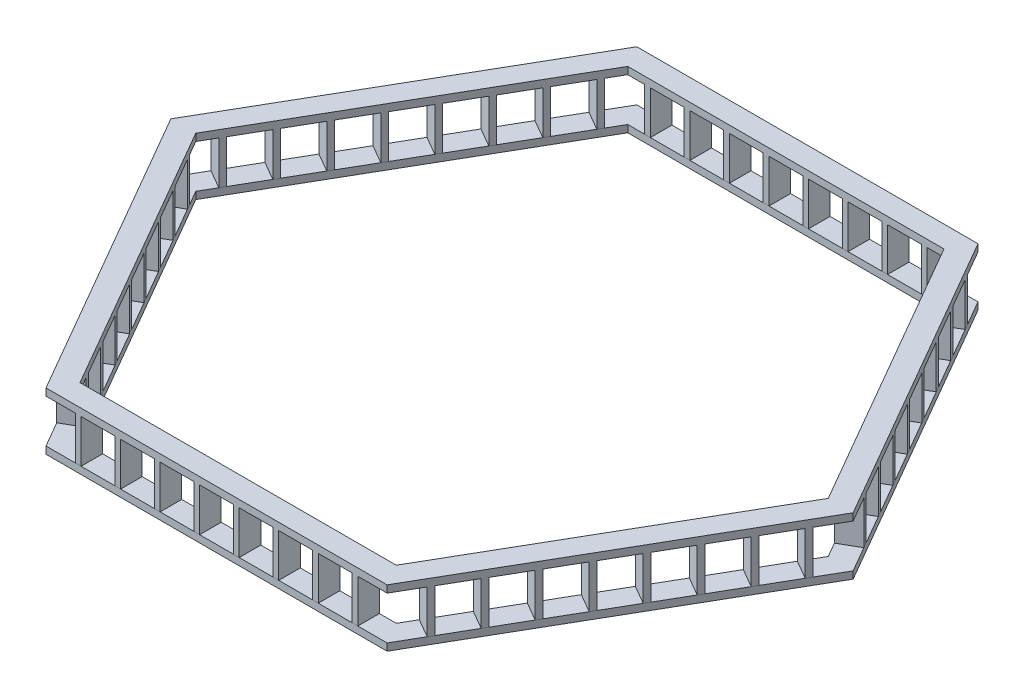
from build123d import *

# Parameters (mm, degrees)
EXTRUDE_2_DEPTH          = 50
SKETCH_2_W               = 40
SKETCH_2_H               = 150
EXTRUDE_3_DEPTH          = 300
EXTRUDE_3_2_DEPTH        = 300
EXTRUDE_3_3_DEPTH        = 300
EXTRUDE_3_4_DEPTH        = 300
EXTRUDE_3_5_DEPTH        = 300
EXTRUDE_3_6_DEPTH        = 300
EXTRUDE_3_7_DEPTH        = 300
EXTRUDE_3_8_DEPTH        = 300
PATTERN_CIRCULAR_2_COUNT = 6
EXTRUDE_5_DEPTH          = 50


with BuildPart() as part:
    # 草图1 → 凸台-拉伸2 (new body)
    with BuildSketch(Plane(origin=(0, 0, 0), x_dir=(1, 0, 0), z_dir=(0, 1, 0))):
        Polygon((-1186.602540378, -2055.255888326), (1186.602540378, -2055.255888326), (2373.205080757, 0), (1186.602540378, 2055.255888326), (-1186.602540378, 2055.255888326), (-2373.205080757, 0), align=None)
        Polygon((-1100, -1905.255888326), (1100, -1905.255888326), (2200, 0), (1100, 1905.255888326), (-1100, 1905.255888326), (-2200, 0), align=None, mode=Mode.SUBTRACT)
    extrude(amount=EXTRUDE_2_DEPTH)


with BuildPart() as body_2:
    # 草图2 → 凸台-拉伸3 (new body)
    with BuildSketch(Plane(origin=(0, 50, 0), x_dir=(1, 0, 0), z_dir=(0, 1, 0))):
        with Locations((137.5, 1980.255888326)):
            Rectangle(SKETCH_2_W, SKETCH_2_H)
    extrude(amount=EXTRUDE_3_DEPTH)


with BuildPart() as body_3:
    # 草图2 → Extrude 3 2 (new body)
    with BuildSketch(Plane(origin=(0, 50, 0), x_dir=(1, 0, 0), z_dir=(0, 1, 0))):
        with Locations((412.5, 1980.255888326)):
            Rectangle(SKETCH_2_W, SKETCH_2_H)
    extrude(amount=EXTRUDE_3_2_DEPTH)


with BuildPart() as body_4:
    # 草图2 → Extrude 3 3 (new body)
    with BuildSketch(Plane(origin=(0, 50, 0), x_dir=(1, 0, 0), z_dir=(0, 1, 0))):
        with Locations((687.5, 1980.255888326)):
            Rectangle(SKETCH_2_W, SKETCH_2_H)
    extrude(amount=EXTRUDE_3_3_DEPTH)


with BuildPart() as body_5:
    # 草图2 → Extrude 3 4 (new body)
    with BuildSketch(Plane(origin=(0, 50, 0), x_dir=(1, 0, 0), z_dir=(0, 1, 0))):
        with Locations((962.5, 1980.255888326)):
            Rectangle(SKETCH_2_W, SKETCH_2_H)
    extrude(amount=EXTRUDE_3_4_DEPTH)


with BuildPart() as body_6:
    # 草图2 → Extrude 3 5 (new body)
    with BuildSketch(Plane(origin=(0, 50, 0), x_dir=(1, 0, 0), z_dir=(0, 1, 0))):
        with Locations((-412.5, 1980.255888326)):
            Rectangle(SKETCH_2_W, SKETCH_2_H)
    extrude(amount=EXTRUDE_3_5_DEPTH)


with BuildPart() as body_7:
    # 草图2 → Extrude 3 6 (new body)
    with BuildSketch(Plane(origin=(0, 50, 0), x_dir=(1, 0, 0), z_dir=(0, 1, 0))):
        with Locations((-962.5, 1980.255888326)):
            Rectangle(SKETCH_2_W, SKETCH_2_H)
    extrude(amount=EXTRUDE_3_6_DEPTH)


with BuildPart() as body_8:
    # 草图2 → Extrude 3 7 (new body)
    with BuildSketch(Plane(origin=(0, 50, 0), x_dir=(1, 0, 0), z_dir=(0, 1, 0))):
        with Locations((-687.5, 1980.255888326)):
            Rectangle(SKETCH_2_W, SKETCH_2_H)
    extrude(amount=EXTRUDE_3_7_DEPTH)


with BuildPart() as body_9:
    # 草图2 → Extrude 3 8 (new body)
    with BuildSketch(Plane(origin=(0, 50, 0), x_dir=(1, 0, 0), z_dir=(0, 1, 0))):
        with Locations((-137.5, 1980.255888326)):
            Rectangle(SKETCH_2_W, SKETCH_2_H)
    extrude(amount=EXTRUDE_3_8_DEPTH)


with BuildPart() as pattern_circular_2_1:
    # 阵列(圆周)2: pattern copy
    add(body_5.part.rotate(Axis((0, 0, 0), (0, 1, 0)), 1 * 360 / PATTERN_CIRCULAR_2_COUNT))


with BuildPart() as pattern_circular_2_2:
    # 阵列(圆周)2: pattern copy
    add(body_5.part.rotate(Axis((0, 0, 0), (0, 1, 0)), 2 * 360 / PATTERN_CIRCULAR_2_COUNT))


with BuildPart() as pattern_circular_2_3:
    # 阵列(圆周)2: pattern copy
    add(body_5.part.rotate(Axis((0, 0, 0), (0, 1, 0)), 3 * 360 / PATTERN_CIRCULAR_2_COUNT))


with BuildPart() as pattern_circular_2_4:
    # 阵列(圆周)2: pattern copy
    add(body_5.part.rotate(Axis((0, 0, 0), (0, 1, 0)), 4 * 360 / PATTERN_CIRCULAR_2_COUNT))


with BuildPart() as pattern_circular_2_5:
    # 阵列(圆周)2: pattern copy
    add(body_5.part.rotate(Axis((0, 0, 0), (0, 1, 0)), 5 * 360 / PATTERN_CIRCULAR_2_COUNT))


with BuildPart() as pattern_circular_2_6:
    # 阵列(圆周)2: pattern copy
    add(body_3.part.rotate(Axis((0, 0, 0), (0, 1, 0)), 1 * 360 / PATTERN_CIRCULAR_2_COUNT))


with BuildPart() as pattern_circular_2_7:
    # 阵列(圆周)2: pattern copy
    add(body_3.part.rotate(Axis((0, 0, 0), (0, 1, 0)), 2 * 360 / PATTERN_CIRCULAR_2_COUNT))


with BuildPart() as pattern_circular_2_8:
    # 阵列(圆周)2: pattern copy
    add(body_3.part.rotate(Axis((0, 0, 0), (0, 1, 0)), 3 * 360 / PATTERN_CIRCULAR_2_COUNT))


with BuildPart() as pattern_circular_2_9:
    # 阵列(圆周)2: pattern copy
    add(body_3.part.rotate(Axis((0, 0, 0), (0, 1, 0)), 4 * 360 / PATTERN_CIRCULAR_2_COUNT))


with BuildPart() as pattern_circular_2_10:
    # 阵列(圆周)2: pattern copy
    add(body_3.part.rotate(Axis((0, 0, 0), (0, 1, 0)), 5 * 360 / PATTERN_CIRCULAR_2_COUNT))


with BuildPart() as pattern_circular_2_11:
    # 阵列(圆周)2: pattern copy
    add(body_7.part.rotate(Axis((0, 0, 0), (0, 1, 0)), 1 * 360 / PATTERN_CIRCULAR_2_COUNT))


with BuildPart() as pattern_circular_2_12:
    # 阵列(圆周)2: pattern copy
    add(body_7.part.rotate(Axis((0, 0, 0), (0, 1, 0)), 2 * 360 / PATTERN_CIRCULAR_2_COUNT))


with BuildPart() as pattern_circular_2_13:
    # 阵列(圆周)2: pattern copy
    add(body_7.part.rotate(Axis((0, 0, 0), (0, 1, 0)), 3 * 360 / PATTERN_CIRCULAR_2_COUNT))


with BuildPart() as pattern_circular_2_14:
    # 阵列(圆周)2: pattern copy
    add(body_7.part.rotate(Axis((0, 0, 0), (0, 1, 0)), 4 * 360 / PATTERN_CIRCULAR_2_COUNT))


with BuildPart() as pattern_circular_2_15:
    # 阵列(圆周)2: pattern copy
    add(body_7.part.rotate(Axis((0, 0, 0), (0, 1, 0)), 5 * 360 / PATTERN_CIRCULAR_2_COUNT))


with BuildPart() as pattern_circular_2_16:
    # 阵列(圆周)2: pattern copy
    add(body_8.part.rotate(Axis((0, 0, 0), (0, 1, 0)), 1 * 360 / PATTERN_CIRCULAR_2_COUNT))


with BuildPart() as pattern_circular_2_17:
    # 阵列(圆周)2: pattern copy
    add(body_8.part.rotate(Axis((0, 0, 0), (0, 1, 0)), 2 * 360 / PATTERN_CIRCULAR_2_COUNT))


with BuildPart() as pattern_circular_2_18:
    # 阵列(圆周)2: pattern copy
    add(body_8.part.rotate(Axis((0, 0, 0), (0, 1, 0)), 3 * 360 / PATTERN_CIRCULAR_2_COUNT))


with BuildPart() as pattern_circular_2_19:
    # 阵列(圆周)2: pattern copy
    add(body_8.part.rotate(Axis((0, 0, 0), (0, 1, 0)), 4 * 360 / PATTERN_CIRCULAR_2_COUNT))


with BuildPart() as pattern_circular_2_20:
    # 阵列(圆周)2: pattern copy
    add(body_8.part.rotate(Axis((0, 0, 0), (0, 1, 0)), 5 * 360 / PATTERN_CIRCULAR_2_COUNT))


with BuildPart() as pattern_circular_2_21:
    # 阵列(圆周)2: pattern copy
    add(body_6.part.rotate(Axis((0, 0, 0), (0, 1, 0)), 1 * 360 / PATTERN_CIRCULAR_2_COUNT))


with BuildPart() as pattern_circular_2_22:
    # 阵列(圆周)2: pattern copy
    add(body_6.part.rotate(Axis((0, 0, 0), (0, 1, 0)), 2 * 360 / PATTERN_CIRCULAR_2_COUNT))


with BuildPart() as pattern_circular_2_23:
    # 阵列(圆周)2: pattern copy
    add(body_6.part.rotate(Axis((0, 0, 0), (0, 1, 0)), 3 * 360 / PATTERN_CIRCULAR_2_COUNT))


with BuildPart() as pattern_circular_2_24:
    # 阵列(圆周)2: pattern copy
    add(body_6.part.rotate(Axis((0, 0, 0), (0, 1, 0)), 4 * 360 / PATTERN_CIRCULAR_2_COUNT))


with BuildPart() as pattern_circular_2_25:
    # 阵列(圆周)2: pattern copy
    add(body_6.part.rotate(Axis((0, 0, 0), (0, 1, 0)), 5 * 360 / PATTERN_CIRCULAR_2_COUNT))


with BuildPart() as pattern_circular_2_26:
    # 阵列(圆周)2: pattern copy
    add(body_9.part.rotate(Axis((0, 0, 0), (0, 1, 0)), 1 * 360 / PATTERN_CIRCULAR_2_COUNT))


with BuildPart() as pattern_circular_2_27:
    # 阵列(圆周)2: pattern copy
    add(body_9.part.rotate(Axis((0, 0, 0), (0, 1, 0)), 2 * 360 / PATTERN_CIRCULAR_2_COUNT))


with BuildPart() as pattern_circular_2_28:
    # 阵列(圆周)2: pattern copy
    add(body_9.part.rotate(Axis((0, 0, 0), (0, 1, 0)), 3 * 360 / PATTERN_CIRCULAR_2_COUNT))


with BuildPart() as pattern_circular_2_29:
    # 阵列(圆周)2: pattern copy
    add(body_9.part.rotate(Axis((0, 0, 0), (0, 1, 0)), 4 * 360 / PATTERN_CIRCULAR_2_COUNT))


with BuildPart() as pattern_circular_2_30:
    # 阵列(圆周)2: pattern copy
    add(body_9.part.rotate(Axis((0, 0, 0), (0, 1, 0)), 5 * 360 / PATTERN_CIRCULAR_2_COUNT))


with BuildPart() as pattern_circular_2_31:
    # 阵列(圆周)2: pattern copy
    add(body_2.part.rotate(Axis((0, 0, 0), (0, 1, 0)), 1 * 360 / PATTERN_CIRCULAR_2_COUNT))


with BuildPart() as pattern_circular_2_32:
    # 阵列(圆周)2: pattern copy
    add(body_2.part.rotate(Axis((0, 0, 0), (0, 1, 0)), 2 * 360 / PATTERN_CIRCULAR_2_COUNT))


with BuildPart() as pattern_circular_2_33:
    # 阵列(圆周)2: pattern copy
    add(body_2.part.rotate(Axis((0, 0, 0), (0, 1, 0)), 3 * 360 / PATTERN_CIRCULAR_2_COUNT))


with BuildPart() as pattern_circular_2_34:
    # 阵列(圆周)2: pattern copy
    add(body_2.part.rotate(Axis((0, 0, 0), (0, 1, 0)), 4 * 360 / PATTERN_CIRCULAR_2_COUNT))


with BuildPart() as pattern_circular_2_35:
    # 阵列(圆周)2: pattern copy
    add(body_2.part.rotate(Axis((0, 0, 0), (0, 1, 0)), 5 * 360 / PATTERN_CIRCULAR_2_COUNT))


with BuildPart() as pattern_circular_2_36:
    # 阵列(圆周)2: pattern copy
    add(body_4.part.rotate(Axis((0, 0, 0), (0, 1, 0)), 1 * 360 / PATTERN_CIRCULAR_2_COUNT))


with BuildPart() as pattern_circular_2_37:
    # 阵列(圆周)2: pattern copy
    add(body_4.part.rotate(Axis((0, 0, 0), (0, 1, 0)), 2 * 360 / PATTERN_CIRCULAR_2_COUNT))


with BuildPart() as pattern_circular_2_38:
    # 阵列(圆周)2: pattern copy
    add(body_4.part.rotate(Axis((0, 0, 0), (0, 1, 0)), 3 * 360 / PATTERN_CIRCULAR_2_COUNT))


with BuildPart() as pattern_circular_2_39:
    # 阵列(圆周)2: pattern copy
    add(body_4.part.rotate(Axis((0, 0, 0), (0, 1, 0)), 4 * 360 / PATTERN_CIRCULAR_2_COUNT))


with BuildPart() as pattern_circular_2_40:
    # 阵列(圆周)2: pattern copy
    add(body_4.part.rotate(Axis((0, 0, 0), (0, 1, 0)), 5 * 360 / PATTERN_CIRCULAR_2_COUNT))


with BuildPart() as body_2_1:
    add(body_2.part)

    add(body_3.part)  # 凸台-拉伸5 merges body 3

    add(body_4.part)  # 凸台-拉伸5 merges body 4

    add(body_5.part)  # 凸台-拉伸5 merges body 5

    add(body_6.part)  # 凸台-拉伸5 merges body 6

    add(body_7.part)  # 凸台-拉伸5 merges body 7

    add(body_8.part)  # 凸台-拉伸5 merges body 8

    add(body_9.part)  # 凸台-拉伸5 merges body 9

    add(pattern_circular_2_1.part)  # 凸台-拉伸5 merges 阵列(圆周)2_1

    add(pattern_circular_2_2.part)  # 凸台-拉伸5 merges 阵列(圆周)2_2

    add(pattern_circular_2_3.part)  # 凸台-拉伸5 merges 阵列(圆周)2_3

    add(pattern_circular_2_4.part)  # 凸台-拉伸5 merges 阵列(圆周)2_4

    add(pattern_circular_2_5.part)  # 凸台-拉伸5 merges 阵列(圆周)2_5

    add(pattern_circular_2_6.part)  # 凸台-拉伸5 merges 阵列(圆周)2_6

    add(pattern_circular_2_7.part)  # 凸台-拉伸5 merges 阵列(圆周)2_7

    add(pattern_circular_2_8.part)  # 凸台-拉伸5 merges 阵列(圆周)2_8

    add(pattern_circular_2_9.part)  # 凸台-拉伸5 merges 阵列(圆周)2_9

    add(pattern_circular_2_10.part)  # 凸台-拉伸5 merges 阵列(圆周)2_10

    add(pattern_circular_2_11.part)  # 凸台-拉伸5 merges 阵列(圆周)2_11

    add(pattern_circular_2_12.part)  # 凸台-拉伸5 merges 阵列(圆周)2_12

    add(pattern_circular_2_13.part)  # 凸台-拉伸5 merges 阵列(圆周)2_13

    add(pattern_circular_2_14.part)  # 凸台-拉伸5 merges 阵列(圆周)2_14

    add(pattern_circular_2_15.part)  # 凸台-拉伸5 merges 阵列(圆周)2_15

    add(pattern_circular_2_16.part)  # 凸台-拉伸5 merges 阵列(圆周)2_16

    add(pattern_circular_2_17.part)  # 凸台-拉伸5 merges 阵列(圆周)2_17

    add(pattern_circular_2_18.part)  # 凸台-拉伸5 merges 阵列(圆周)2_18

    add(pattern_circular_2_19.part)  # 凸台-拉伸5 merges 阵列(圆周)2_19

    add(pattern_circular_2_20.part)  # 凸台-拉伸5 merges 阵列(圆周)2_20

    add(pattern_circular_2_21.part)  # 凸台-拉伸5 merges 阵列(圆周)2_21

    add(pattern_circular_2_22.part)  # 凸台-拉伸5 merges 阵列(圆周)2_22

    add(pattern_circular_2_23.part)  # 凸台-拉伸5 merges 阵列(圆周)2_23

    add(pattern_circular_2_24.part)  # 凸台-拉伸5 merges 阵列(圆周)2_24

    add(pattern_circular_2_25.part)  # 凸台-拉伸5 merges 阵列(圆周)2_25

    add(pattern_circular_2_26.part)  # 凸台-拉伸5 merges 阵列(圆周)2_26

    add(pattern_circular_2_27.part)  # 凸台-拉伸5 merges 阵列(圆周)2_27

    add(pattern_circular_2_28.part)  # 凸台-拉伸5 merges 阵列(圆周)2_28

    add(pattern_circular_2_29.part)  # 凸台-拉伸5 merges 阵列(圆周)2_29

    add(pattern_circular_2_30.part)  # 凸台-拉伸5 merges 阵列(圆周)2_30

    add(pattern_circular_2_31.part)  # 凸台-拉伸5 merges 阵列(圆周)2_31

    add(pattern_circular_2_32.part)  # 凸台-拉伸5 merges 阵列(圆周)2_32

    add(pattern_circular_2_33.part)  # 凸台-拉伸5 merges 阵列(圆周)2_33

    add(pattern_circular_2_34.part)  # 凸台-拉伸5 merges 阵列(圆周)2_34

    add(pattern_circular_2_35.part)  # 凸台-拉伸5 merges 阵列(圆周)2_35

    add(pattern_circular_2_36.part)  # 凸台-拉伸5 merges 阵列(圆周)2_36

    add(pattern_circular_2_37.part)  # 凸台-拉伸5 merges 阵列(圆周)2_37

    add(pattern_circular_2_38.part)  # 凸台-拉伸5 merges 阵列(圆周)2_38

    add(pattern_circular_2_39.part)  # 凸台-拉伸5 merges 阵列(圆周)2_39

    add(pattern_circular_2_40.part)  # 凸台-拉伸5 merges 阵列(圆周)2_40
    # 草图5 → 凸台-拉伸5 (add)
    with BuildSketch(Plane(origin=(0, 350, 0), x_dir=(1, 0, 0), z_dir=(0, 1, 0))):
        Polygon((-2373.205080757, 0), (-1186.602540378, -2055.255888326), (1186.602540378, -2055.255888326), (2373.205080757, 0), (1186.602540378, 2055.255888326), (-1186.602540378, 2055.255888326), align=None)
        Polygon((-2200, 0), (-1100, -1905.255888326), (1100, -1905.255888326), (2200, 0), (1100, 1905.255888326), (-1100, 1905.255888326), align=None, mode=Mode.SUBTRACT)
    extrude(amount=EXTRUDE_5_DEPTH)


solid = Compound([part.part, body_2_1.part])
